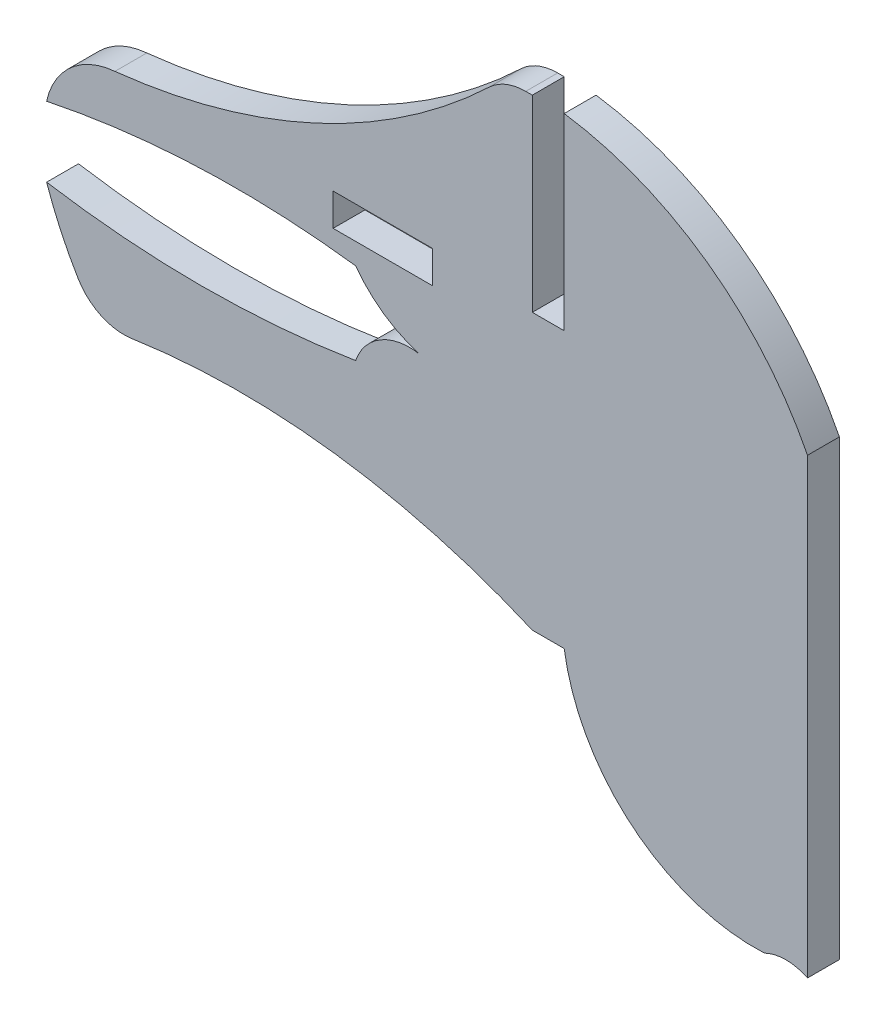
from build123d import *

# Parameters (mm, degrees)
SKETCH1_W           = 4.7625
SKETCH1_H           = 1.545684244
BOSS_EXTRUDE1_DEPTH = 1.524


with BuildPart() as part:
    # Sketch1 → Boss-Extrude1 (new body)
    with BuildSketch(Plane.XY):
        with BuildLine():
            Line((0, 15.440411119), (-1.524, 15.440411119))
            Line((-1.524, 15.440411119), (-1.524, 24.435175852))
            Line((-1.524, 24.435175852), (-1.836778674, 24.435175852))
            ThreePointArc((-1.836778674, 24.435175852), (-2.780560258, 24.253326891), (-3.589203495, 23.733818626))
            ThreePointArc((-3.589203495, 23.733818626), (-11.850131673, 18.109761084), (-21.480683494, 15.440411119))
            ThreePointArc((-21.480683494, 15.440411119), (-23.587055129, 14.543073006), (-24.747192379, 12.569219234))
            ThreePointArc((-24.747192379, 12.569219234), (-17.383897912, 13.471716361), (-9.972791779, 13.142911901))
            ThreePointArc((-9.972791779, 13.142911901), (-8.617730977, 11.821371906), (-6.905922332, 11.013678341))
            ThreePointArc((-6.905922332, 11.013678341), (-8.770219675, 10.681853269), (-9.972791779, 9.219139081))
            ThreePointArc((-9.972791779, 9.219139081), (-17.359992079, 8.625773055), (-24.747192379, 9.219139081))
            ThreePointArc((-24.747192379, 9.219139081), (-24.079326319, 7.561664754), (-23.241579524, 5.983233086))
            ThreePointArc((-23.241579524, 5.983233086), (-22.148302871, 4.993292395), (-20.68927527, 4.777712082))
            ThreePointArc((-20.68927527, 4.777712082), (-10.932367406, 4.867164845), (-1.524, 2.281072115))
            Line((-1.524, 2.281072115), (0, 2.281072115))
            ThreePointArc((0, 2.281072115), (3.282961886, -3.471531025), (9.573778774, -5.544187416))
            ThreePointArc((9.573778774, -5.544187416), (10.603851301, -5.306050671), (11.633923828, -5.544187416))
            Line((11.633923828, -5.544187416), (11.633923828, 16.100831607))
            ThreePointArc((11.633923828, 16.100831607), (6.837865982, 21.693085274), (0, 24.435175852))
            Line((0, 24.435175852), (0, 15.440411119))
        make_face()
        with Locations((-8.66775, 14.92904471)):
            Rectangle(SKETCH1_W, SKETCH1_H, mode=Mode.SUBTRACT)
    extrude(amount=BOSS_EXTRUDE1_DEPTH)


solid = part.part
